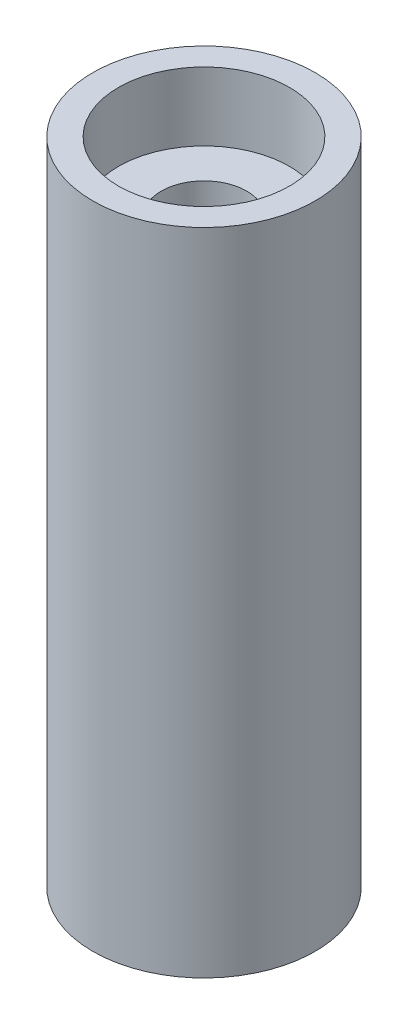
from build123d import *

# Parameters (mm, degrees)
SKETCH_1_R          = 6.5
SKETCH_1_R_2        = 2.5
EXTRUDE_2_DEPTH     = 19
SKETCH_2_R          = 5
CUT_EXTRUDE_1_DEPTH = 4


with BuildPart() as part:
    # 草图1 → 凸台-拉伸2 (new body, symmetric)
    with BuildSketch(Plane(origin=(0, 0, 0), x_dir=(1, 0, 0), z_dir=(0, 1, 0))):
        Circle(SKETCH_1_R)
        Circle(SKETCH_1_R_2, mode=Mode.SUBTRACT)
    extrude(amount=EXTRUDE_2_DEPTH, both=True)

    # 草图2 → 切除-拉伸1 (cut)
    with BuildSketch(Plane(origin=(0, 19, 0), x_dir=(1, 0, 0), z_dir=(0, 1, 0))):
        Circle(SKETCH_2_R)
    cut_extrude_1 = extrude(amount=-CUT_EXTRUDE_1_DEPTH, mode=Mode.SUBTRACT)

    # 镜向1: 切除-拉伸1 across plane
    add(cut_extrude_1.mirror(Plane.ZX), mode=Mode.SUBTRACT)


solid = part.part
